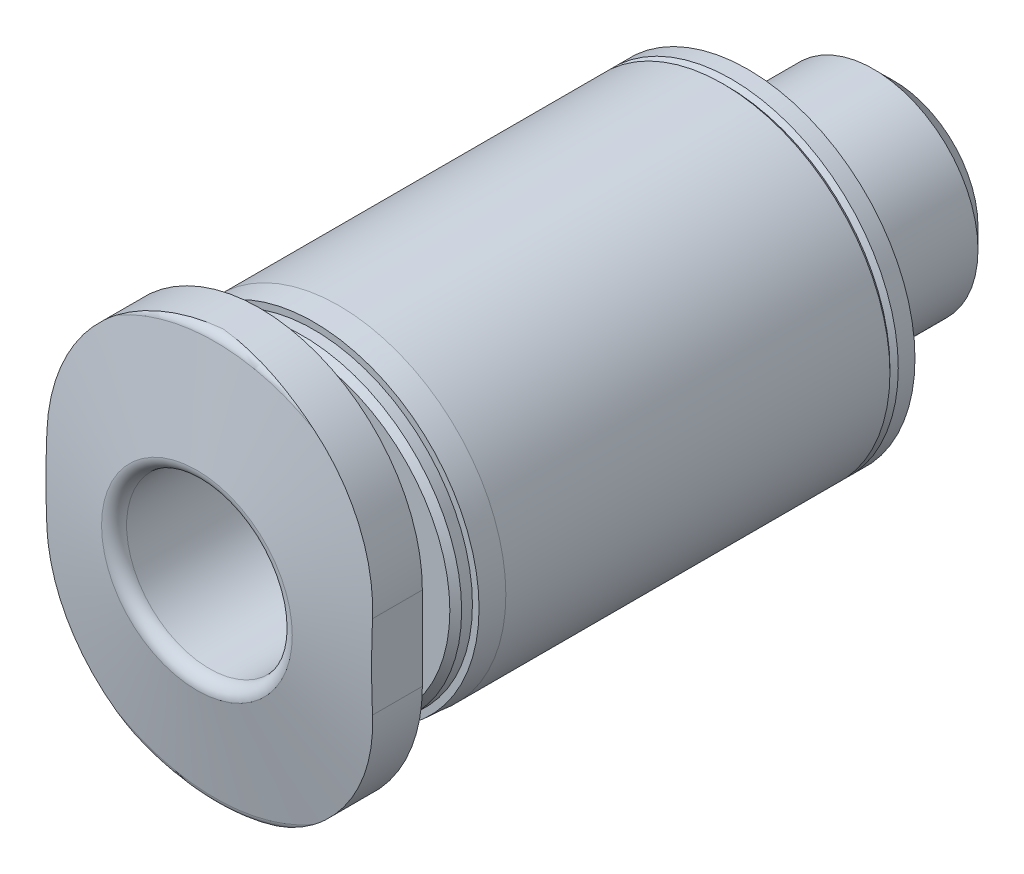
from build123d import *

# Parameters (mm, degrees)
SKETCH2_W          = 19.6
SKETCH2_H          = 19.6
CUT_EXTRUDE1_DEPTH = 1.5
CUT_EXTRUDE2_DEPTH = 5.2


with BuildPart() as part:
    # Sketch1 → Revolve1 (revolve)
    with BuildSketch(Plane(origin=(0, 0, 0), x_dir=(0, 0, -1), z_dir=(1, 0, 0))):
        with BuildLine():
            Line((-13.2, 0), (-13.2, 2.2845))
            Line((-13.2, 2.2845), (-12.767958406, 4.734729636))
            ThreePointArc((-12.767958406, 4.734729636), (-12.699554378, 4.853208889), (-12.570996856, 4.9))
            Line((-12.570996856, 4.9), (-11.7, 4.9))
            Line((-11.7, 4.9), (-11.7, 3.0595))
            ThreePointArc((-11.7, 3.0595), (-11.590165043, 2.794334957), (-11.325, 2.6845))
            Line((-11.325, 2.6845), (-10.8, 2.6845))
            Line((-10.8, 2.6845), (-10.8, 3.658578644))
            Line((-10.8, 3.658578644), (-10.658578644, 3.8))
            Line((-10.658578644, 3.8), (-10.4, 3.8))
            Line((-10.4, 3.8), (-10.4, 3.958043913))
            Line((-10.4, 3.958043913), (-9.8, 4))
            Line((-9.8, 4), (-0.6, 4))
            Line((-0.6, 4), (-0.5, 3.9))
            Line((-0.5, 3.9), (-0.4, 4))
            Line((-0.4, 4), (0, 4))
            Line((0, 4), (0, 2.5))
            Line((0, 2.5), (3.0095, 2.5))
            Line((3.0095, 2.5), (3.5, 2.0095))
            Line((3.5, 2.0095), (3.5, 0))
            Line((3.5, 0), (-13.2, 0))
        make_face()
    revolve(axis=Axis((0, 0, -3.5), (0, 0, 1)))

    # Sketch2 → Cut-Extrude1 (cut)
    with BuildSketch(Plane.XY.offset(13.2)):
        Rectangle(SKETCH2_W, SKETCH2_H)
        with BuildLine():
            Line((-3.9, 1), (-3.9, -1))
            ThreePointArc((-3.9, -1), (0, -4.9), (3.9, -1))
            Line((3.9, -1), (3.9, 1))
            ThreePointArc((3.9, 1), (0, 4.9), (-3.9, 1))
        make_face(mode=Mode.SUBTRACT)
    extrude(amount=-CUT_EXTRUDE1_DEPTH, mode=Mode.SUBTRACT)

    # Sketch3 → Cut-Extrude2 (cut)
    with BuildSketch(Plane.XY.offset(-3.5)):
        Polygon((-1.25, -0.721687836), (0, -1.443375673), (1.25, -0.721687836), (1.25, 0.721687836), (0, 1.443375673), (-1.25, 0.721687836), align=None)
    extrude(amount=CUT_EXTRUDE2_DEPTH, mode=Mode.SUBTRACT)

    # Sketch4 → Cut-Revolve1 (revolve, cut)
    with BuildSketch(Plane(origin=(0, 0, 0), x_dir=(0, 0, -1), z_dir=(1, 0, 0))):
        with BuildLine():
            Line((-13.2, 0), (-13.2, 2.2845))
            ThreePointArc((-13.2, 2.2845), (-13.112132034, 2.072367966), (-12.9, 1.9845))
            Line((-12.9, 1.9845), (-1.7, 1.9845))
            Line((-1.7, 1.9845), (-1.7, 0))
            Line((-1.7, 0), (-13.2, 0))
        make_face()
    revolve(axis=Axis((0, 0, 1.7), (0, 0, 1)), mode=Mode.SUBTRACT)


solid = part.part
